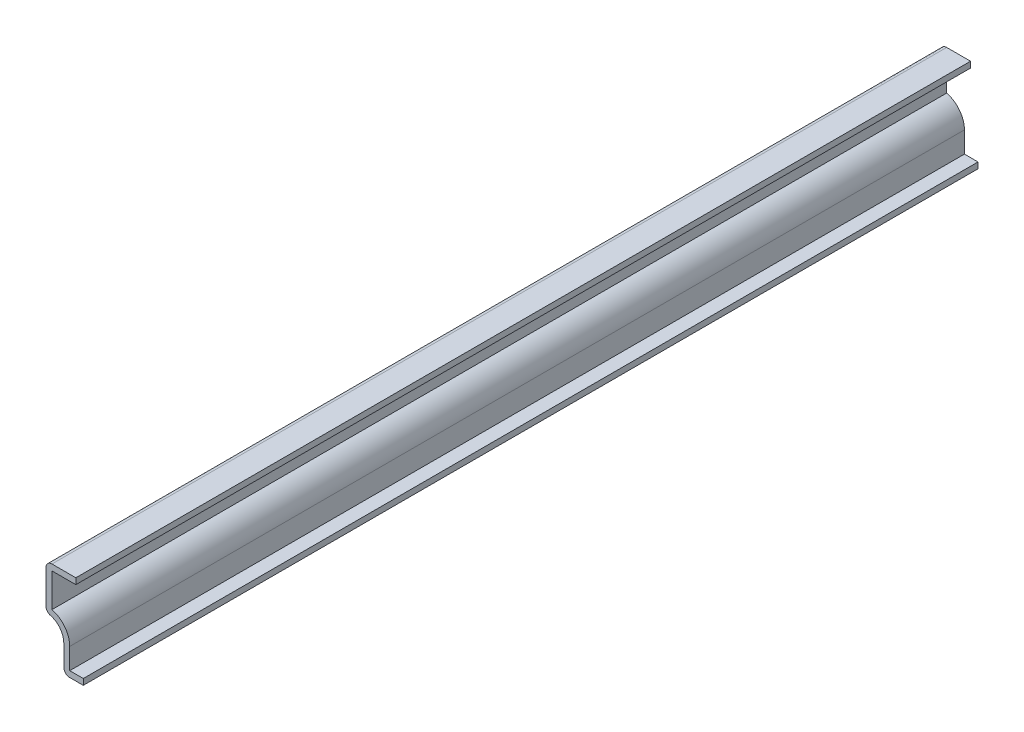
from build123d import *

# Parameters (mm, degrees)
EXTRUDE_THIN1_DEPTH = 190.5
FILLET1_R           = 1.27


with BuildPart() as part:
    # Sketch1 → Extrude-Thin1 (new body)
    with BuildSketch(Plane.XY):
        with BuildLine():
            Line((0, 0), (-4.1550082, 0))
            Line((-4.1550082, 0), (-4.1550082, 5.7425082))
            ThreePointArc((-4.1550082, 5.7425082), (-5.262874398, 8.417133802), (-7.9375, 9.525))
            Line((-7.9375, 9.525), (-7.9375, 19.05))
            Line((-7.9375, 19.05), (-1.5875, 19.05))
            Line((-1.5875, 19.05), (-1.5875, 17.78))
            Line((-1.5875, 17.78), (-6.6675, 17.78))
            Line((-6.6675, 17.78), (-6.6675, 10.632781545))
            ThreePointArc((-6.6675, 10.632781545), (-3.940980391, 8.833706091), (-2.8850082, 5.7425082))
            Line((-2.8850082, 5.7425082), (-2.8850082, 1.27))
            Line((-2.8850082, 1.27), (0, 1.27))
            Line((0, 1.27), (0, 0))
        make_face()
    extrude(amount=-EXTRUDE_THIN1_DEPTH)

    # Fillet1
    fillet1_edges = [part.edges().sort_by_distance(p)[0] for p in [
        (-4.1550082, 0, -95.25),
        (-7.9375, 9.525, -95.25),
        (-7.9375, 19.05, -95.25),
    ]]
    fillet(fillet1_edges, radius=FILLET1_R)


solid = part.part
